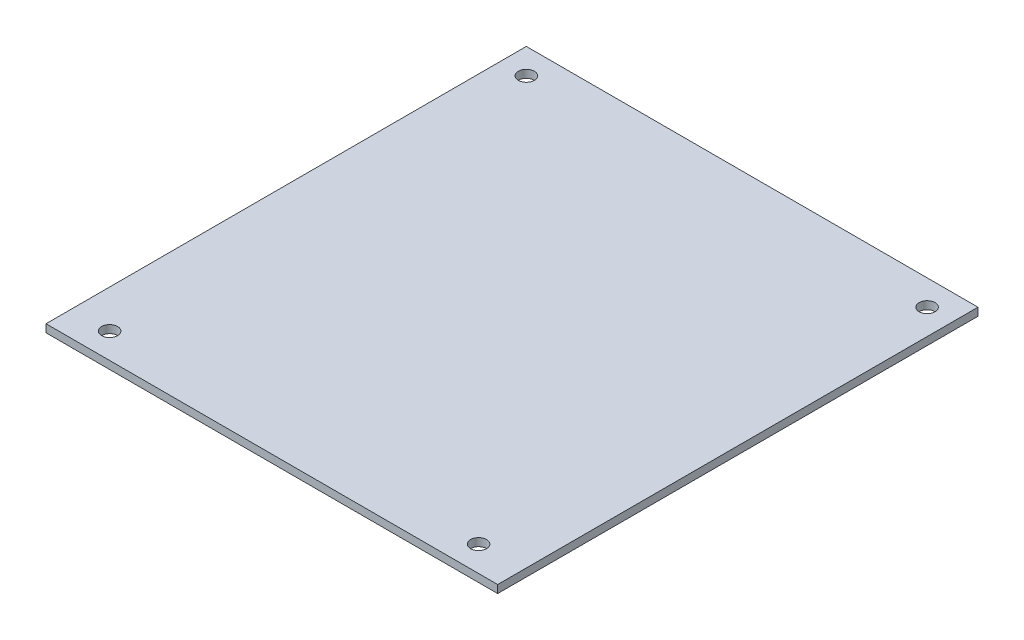
from build123d import *

# Parameters (mm, degrees)
SKETCH1_W           = 90.17
SKETCH1_H           = 95.89
SKETCH1_R           = 1.59
BOSS_EXTRUDE1_DEPTH = 0.785


with BuildPart() as part:
    # Sketch1 → Boss-Extrude1 (new body, symmetric)
    with BuildSketch(Plane(origin=(0, 0, 0), x_dir=(1, 0, 0), z_dir=(0, 1, 0))):
        Rectangle(SKETCH1_W, SKETCH1_H)
        with Locations((-40.005, 42.865)):
            Circle(SKETCH1_R, mode=Mode.SUBTRACT)
        with Locations((-37.465, -42.865)):
            Circle(SKETCH1_R, mode=Mode.SUBTRACT)
        with Locations((36.195, -42.865)):
            Circle(SKETCH1_R, mode=Mode.SUBTRACT)
        with Locations((40.005, 42.865)):
            Circle(SKETCH1_R, mode=Mode.SUBTRACT)
    extrude(amount=BOSS_EXTRUDE1_DEPTH, both=True)


solid = part.part
